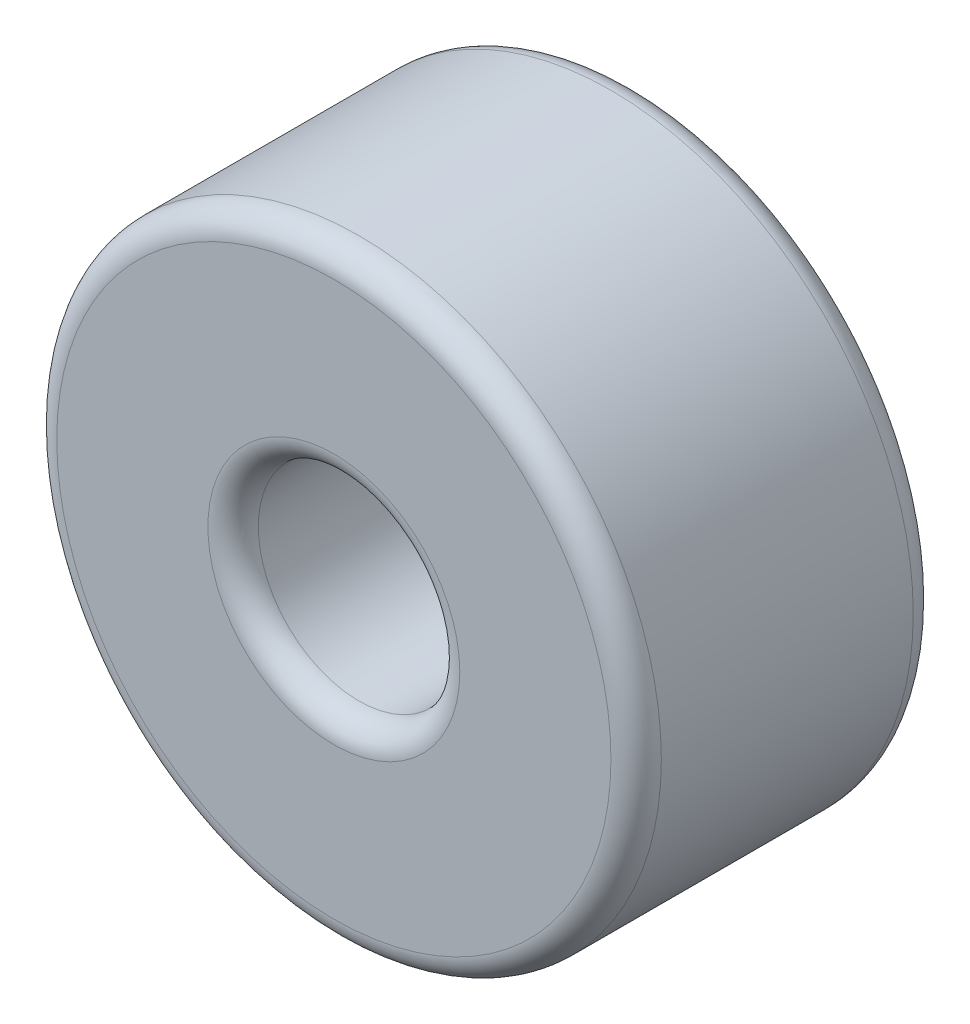
from build123d import *

# Parameters (mm, degrees)
SKETCH1_R           = 3
SKETCH1_R_2         = 1
EXTRUDE_THIN1_DEPTH = 3
FILLET2_R           = 0.25


with BuildPart() as part:
    # Sketch1 → Extrude-Thin1 (new body)
    with BuildSketch(Plane.XY):
        Circle(SKETCH1_R)
        Circle(SKETCH1_R_2, mode=Mode.SUBTRACT)
    extrude(amount=EXTRUDE_THIN1_DEPTH)

    # Fillet2
    fillet2_edges = [part.edges().sort_by_distance(p)[0] for p in [
        (-3, 0, 0),
        (-1, 0, 0),
        (-3, 0, 3),
        (-1, 0, 3),
    ]]
    fillet(fillet2_edges, radius=FILLET2_R)


solid = part.part
